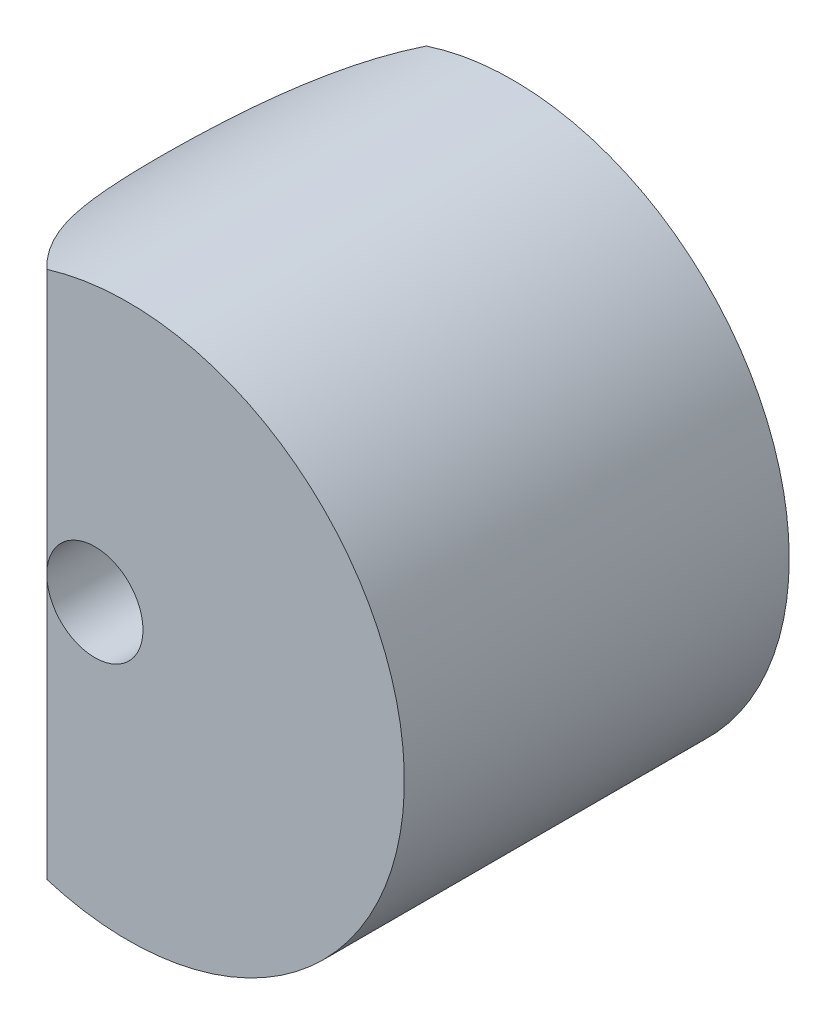
from build123d import *

# Parameters (mm, degrees)
SKETCH1_W               = 57.45
SKETCH1_H               = 80
CUT_EXTRUDE1_DEPTH      = 58.45
CUT_EXTRUDE1_DEPTH_BACK = 58.45
SKETCH3_R               = 10
CUT_EXTRUDE3_DEPTH      = 81.0000001


with BuildPart() as part:
    # Sketch1 → Revolve2 (revolve)
    with BuildSketch(Plane(origin=(0, 0, 0), x_dir=(1, 0, 0), z_dir=(0, 1, 0))):
        with Locations((28.725, 0)):
            Rectangle(SKETCH1_W, SKETCH1_H)
    revolve(axis=Axis((0, 0, 40), (0, 0, -1)))

    # Sketch2 → Cut-Extrude1 (cut, two sides)
    with BuildSketch(Plane(origin=(0, 0, 0), x_dir=(1, 0, 0), z_dir=(0, 1, 0))) as cut_extrude1_sk:
        with BuildLine():
            Line((-18.006693033, 40), (-57.45, 40))
            Line((-57.45, 40), (-57.45, -40))
            Line((-57.45, -40), (-16.882331675, -40))
            ThreePointArc((-16.882331675, -40), (-34.014765262, -0.232886901), (-18.006693033, 40))
        make_face()
    extrude(amount=CUT_EXTRUDE1_DEPTH, mode=Mode.SUBTRACT)
    extrude(cut_extrude1_sk.sketch, amount=-CUT_EXTRUDE1_DEPTH_BACK, mode=Mode.SUBTRACT)

    # Sketch3 → Cut-Extrude3 (cut, through all)
    with BuildSketch(Plane.XY.offset(40)):
        with Locations((-6.882331675, 0)):
            Circle(SKETCH3_R)
    extrude(amount=-CUT_EXTRUDE3_DEPTH, mode=Mode.SUBTRACT)


solid = part.part
